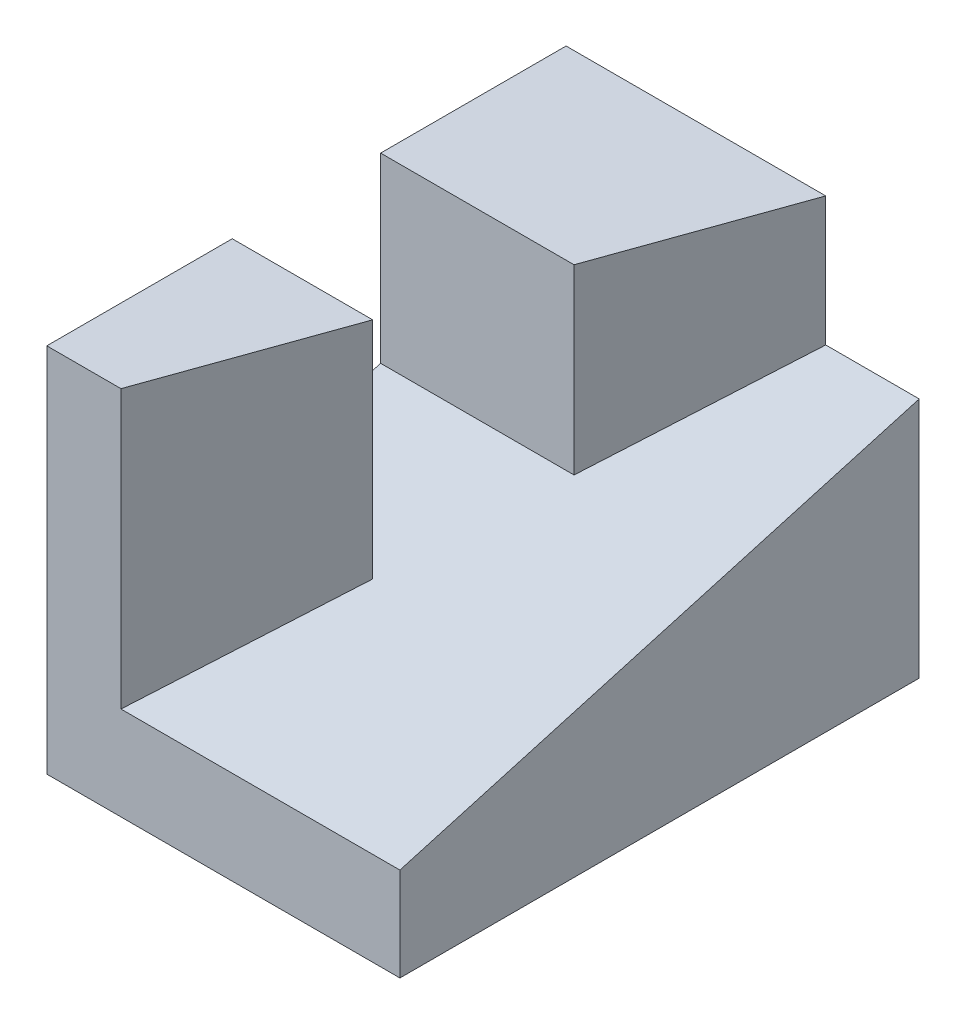
from build123d import *

# Parameters (mm, degrees)
SKETCH3_W           = 60.452
SKETCH3_H           = 88.9
BOSS_EXTRUDE1_DEPTH = 63.5
CUT_EXTRUDE1_DEPTH  = 63.5
BOSS_EXTRUDE2_DEPTH = 63.5


with BuildPart() as part:
    # Sketch3 → Boss-Extrude1 (new body)
    with BuildSketch(Plane(origin=(0, 0, 0), x_dir=(1, 0, 0), z_dir=(0, 1, 0))):
        with Locations((30.226, 44.45)):
            Rectangle(SKETCH3_W, SKETCH3_H)
    extrude(amount=BOSS_EXTRUDE1_DEPTH)

    # Sketch4 → Cut-Extrude1 (cut)
    with BuildSketch(Plane(origin=(0, 0, 0), x_dir=(0, 0, -1), z_dir=(1, 0, 0))):
        Polygon((0, 16.002), (88.9, 41.402), (88.9, 63.5), (0, 63.5), align=None)
    extrude(amount=CUT_EXTRUDE1_DEPTH, mode=Mode.SUBTRACT)

    # Sketch5 → Boss-Extrude2 (add)
    with BuildSketch(Plane(origin=(0, 0, 0), x_dir=(1, 0, 0), z_dir=(0, 1, 0))):
        Polygon((33.110714286, 57.15), (44.45, 88.9), (18.107802509, 88.9), (0, 88.9), (0, 57.15), align=None)
        Polygon((12.7, 0), (24.039285714, 31.75), (0, 31.75), (0, 0), align=None)
    extrude(amount=BOSS_EXTRUDE2_DEPTH)


solid = part.part
